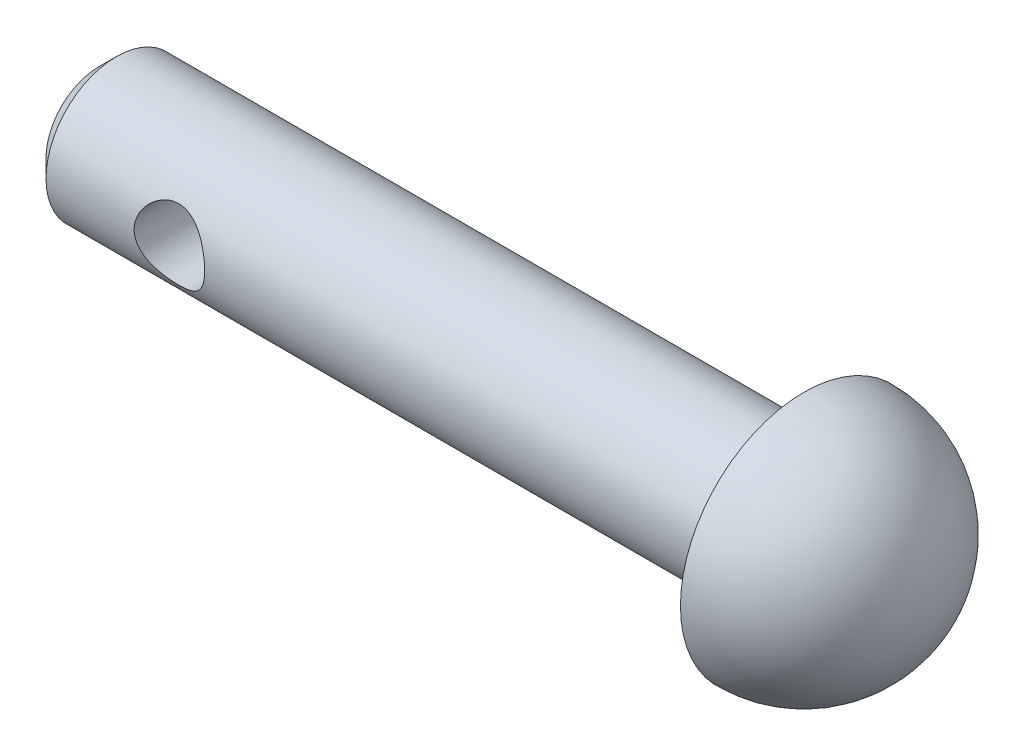
from build123d import *

# Parameters (mm, degrees)
SKETCH4_R               = 1
CUT_EXTRUDE1_DEPTH      = 4.5
CUT_EXTRUDE1_DEPTH_BACK = 4.5
CHAMFER1_SIZE           = 0.5


with BuildPart() as part:
    # Sketch3 → Revolve1 (revolve)
    with BuildSketch(Plane.XY):
        with BuildLine():
            Line((-20, 0), (-20, 2))
            Line((-20, 2), (0, 2))
            Line((0, 2), (0, 3.5))
            ThreePointArc((0, 3.5), (2.474873734, 2.474873734), (3.5, 0))
            Line((3.5, 0), (-20, 0))
        make_face()
    revolve(axis=Axis((-20, 0, 0), (1, 0, 0)))

    # Sketch4 → Cut-Extrude1 (cut, two sides)
    with BuildSketch(Plane.XY) as cut_extrude1_sk:
        with Locations((-16, 0)):
            Circle(SKETCH4_R)
    extrude(amount=CUT_EXTRUDE1_DEPTH, mode=Mode.SUBTRACT)
    extrude(cut_extrude1_sk.sketch, amount=-CUT_EXTRUDE1_DEPTH_BACK, mode=Mode.SUBTRACT)

    # Chamfer1
    chamfer1_edges = [part.edges().sort_by_distance(p)[0] for p in [
        (-20, -2, 0),
    ]]
    chamfer(chamfer1_edges, length=CHAMFER1_SIZE)


solid = part.part
